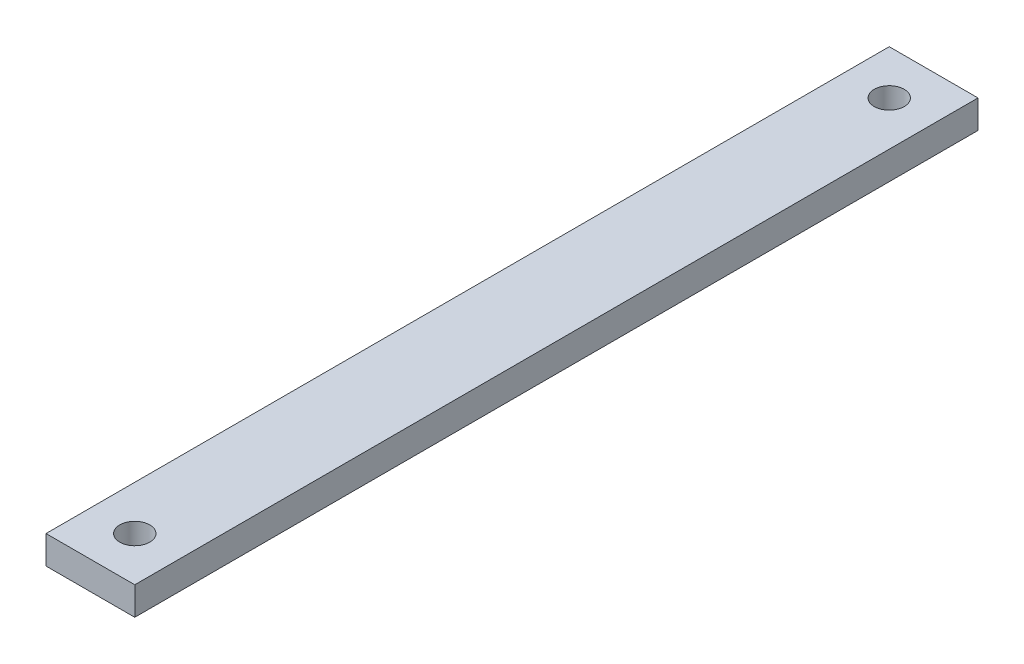
from build123d import *

# Parameters (mm, degrees)
SKETCH1_W           = 20
SKETCH1_H           = 190
SKETCH1_R           = 3.38
BOSS_EXTRUDE1_DEPTH = 6.35


with BuildPart() as part:
    # Sketch1 → Boss-Extrude1 (new body)
    with BuildSketch(Plane(origin=(0, 0, 0), x_dir=(1, 0, 0), z_dir=(0, 1, 0))):
        with Locations((10, 95)):
            Rectangle(SKETCH1_W, SKETCH1_H)
        with Locations((10, 10)):
            Circle(SKETCH1_R, mode=Mode.SUBTRACT)
        with Locations((10, 180)):
            Circle(SKETCH1_R, mode=Mode.SUBTRACT)
    extrude(amount=BOSS_EXTRUDE1_DEPTH)


solid = part.part
